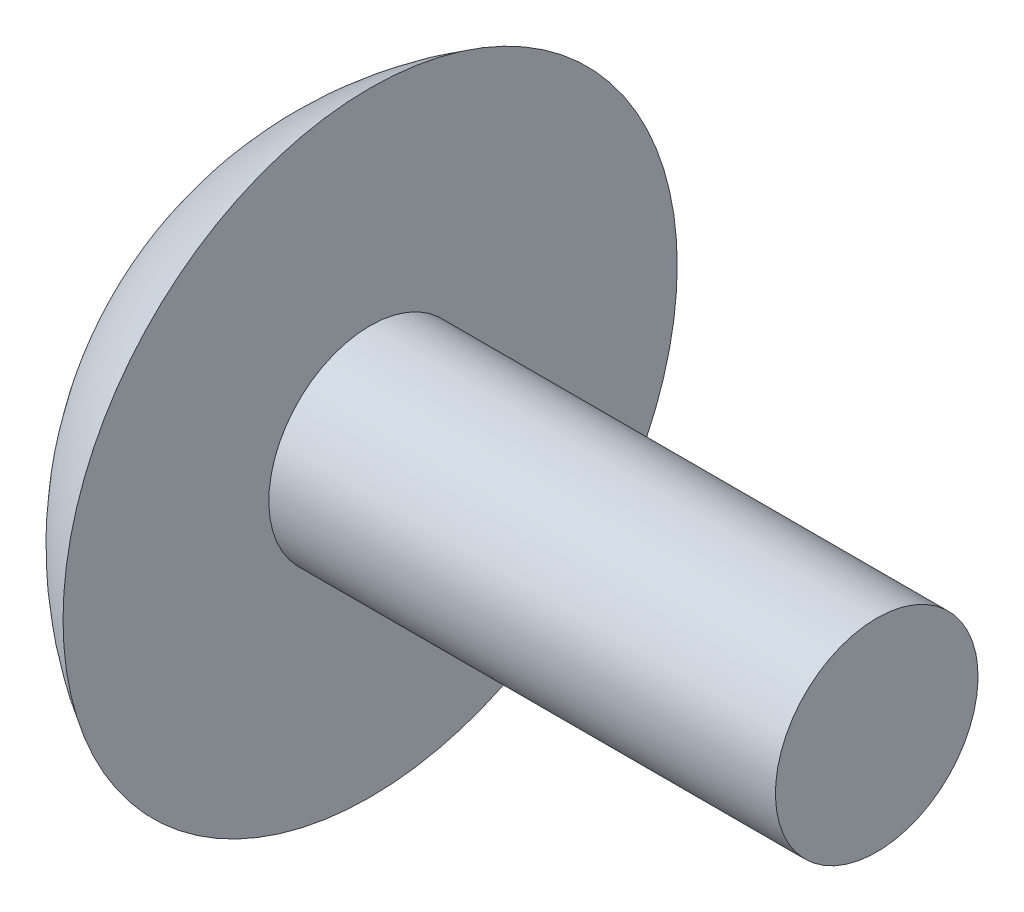
from build123d import *


with BuildPart() as part:
    # Esquisse5 → Révolution2 (revolve)
    with BuildSketch(Plane.XY):
        with BuildLine():
            Line((0, 0), (-13.5, 0))
            ThreePointArc((-13.5, 0), (-12.562177826, -3.5), (-10, -6.062177826))
            Line((-10, -6.062177826), (-10, -2))
            Line((-10, -2), (0, -2))
            Line((0, -2), (0, 0))
        make_face()
    revolve(axis=Axis((0, 0, 0), (-1, 0, 0)))


solid = part.part
